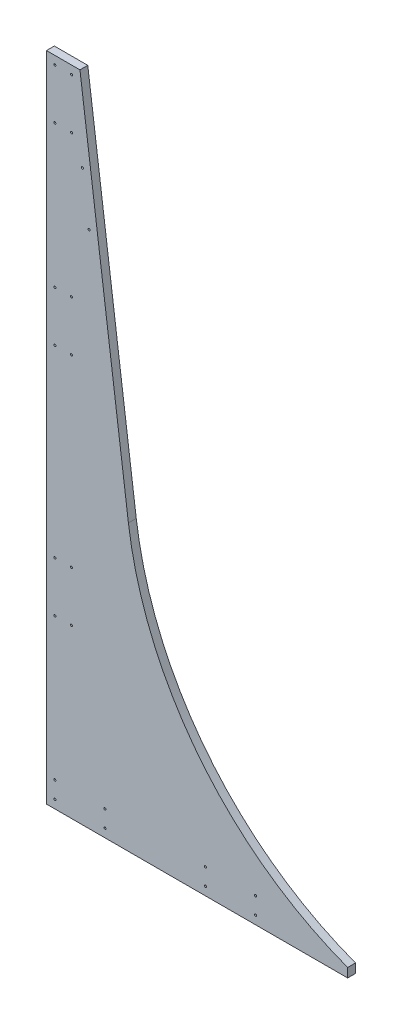
from build123d import *

# Parameters (mm, degrees)
BOSS_EXTRUDE1_DEPTH = 11.90625
SKETCH2_R           = 1.5875
CUT_EXTRUDE1_DEPTH  = 12.90625
SKETCH3_R           = 1.5875
CUT_EXTRUDE2_DEPTH  = 12.90625


with BuildPart() as part:
    # Sketch1 → Boss-Extrude1 (new body)
    with BuildSketch(Plane.XY):
        with BuildLine():
            Line((0, 990.6), (0, 0))
            Line((0, 0), (457.201, 0))
            Line((457.201, 0), (457.201, 13.862038208))
            ThreePointArc((457.201, 13.862038208), (232.767577124, 176.628269142), (124.367415652, 431.8))
            Line((124.367415652, 431.8), (50.8, 990.6))
            Line((50.8, 990.6), (0, 990.6))
        make_face()
    extrude(amount=BOSS_EXTRUDE1_DEPTH)

    # Sketch2 → Cut-Extrude1 (cut, through all)
    with BuildSketch(Plane.XY.offset(11.90625)):
        with Locations((12.7, 977.9)):
            Circle(SKETCH2_R)
        with Locations((38.1, 977.9)):
            Circle(SKETCH2_R)
        with Locations((12.7, 901.7)):
            Circle(SKETCH2_R)
        with Locations((38.1, 901.7)):
            Circle(SKETCH2_R)
        with Locations((12.7, 609.6)):
            Circle(SKETCH2_R)
        with Locations((38.1, 609.6)):
            Circle(SKETCH2_R)
        with Locations((12.7, 685.8)):
            Circle(SKETCH2_R)
        with Locations((38.1, 685.8)):
            Circle(SKETCH2_R)
        with Locations((12.7, 254)):
            Circle(SKETCH2_R)
        with Locations((38.1, 254)):
            Circle(SKETCH2_R)
        with Locations((12.7, 330.2)):
            Circle(SKETCH2_R)
        with Locations((38.1, 330.2)):
            Circle(SKETCH2_R)
        with Locations((12.7, 38.1)):
            Circle(SKETCH2_R)
        with Locations((12.7, 12.7)):
            Circle(SKETCH2_R)
        with Locations((88.9, 38.1)):
            Circle(SKETCH2_R)
        with Locations((88.9, 12.7)):
            Circle(SKETCH2_R)
        with Locations((241.3, 38.1)):
            Circle(SKETCH2_R)
        with Locations((317.5, 38.1)):
            Circle(SKETCH2_R)
        with Locations((241.3, 12.7)):
            Circle(SKETCH2_R)
        with Locations((317.5, 12.7)):
            Circle(SKETCH2_R)
    extrude(amount=-CUT_EXTRUDE1_DEPTH, mode=Mode.SUBTRACT)

    # Sketch3 → Cut-Extrude2 (cut, through all)
    with BuildSketch(Plane.XY.offset(11.90625)):
        with Locations((64.74219971, 787.4)):
            Circle(SKETCH3_R)
        with Locations((54.710279394, 863.6)):
            Circle(SKETCH3_R)
    extrude(amount=-CUT_EXTRUDE2_DEPTH, mode=Mode.SUBTRACT)


solid = part.part
